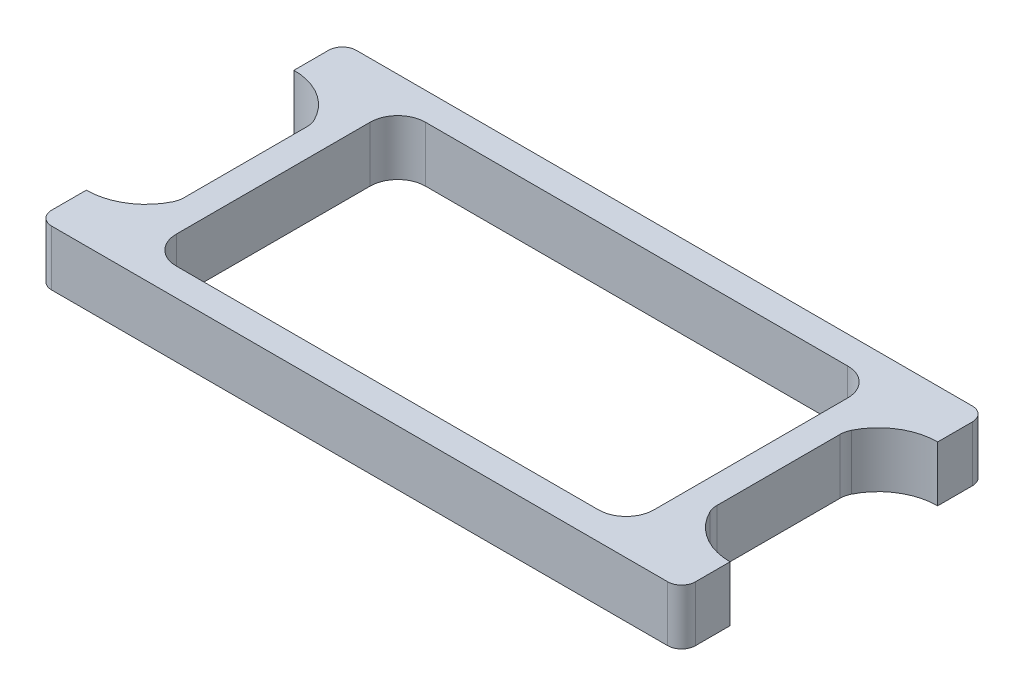
from build123d import *

# Parameters (mm, degrees)
SKETCH1_W            = 93
SKETCH1_H            = 44
BOSS_EXTRUDE1_DEPTH  = 8
SKETCH2_W            = 69
SKETCH2_H            = 36
CUT_EXTRUDE1_DEPTH   = 8
FILLET1_R            = 4
FILLET2_R            = 2
CUT_EXTRUDE2_START   = -9
CUT_EXTRUDE2_DEPTH   = 10
FILLET3_R            = 3
FILLET3_OF_MIRROR1_R = 3


with BuildPart() as part:
    # Sketch1 → Boss-Extrude1 (new body)
    with BuildSketch(Plane(origin=(0, 0, 0), x_dir=(1, 0, 0), z_dir=(0, 1, 0))):
        Rectangle(SKETCH1_W, SKETCH1_H)
    extrude(amount=BOSS_EXTRUDE1_DEPTH)

    # Sketch2 → Cut-Extrude1 (cut)
    with BuildSketch(Plane(origin=(0, 8, 0), x_dir=(1, 0, 0), z_dir=(0, 1, 0))):
        Rectangle(SKETCH2_W, SKETCH2_H)
    extrude(amount=-CUT_EXTRUDE1_DEPTH, mode=Mode.SUBTRACT)

    # Fillet1
    fillet1_edges = [part.edges().sort_by_distance(p)[0] for p in [
        (34.5, 4, 18),
        (-34.5, 4, 18),
        (-34.5, 4, -18),
        (34.5, 4, -18),
    ]]
    fillet(fillet1_edges, radius=FILLET1_R)

    # Fillet2
    fillet2_edges = [part.edges().sort_by_distance(p)[0] for p in [
        (-46.5, 4, -22),
        (46.5, 4, -22),
        (46.5, 4, 22),
        (-46.5, 4, 22),
    ]]
    fillet(fillet2_edges, radius=FILLET2_R)

    # Sketch3 → Cut-Extrude2 (cut)
    with BuildSketch(Plane(origin=(0, 8, 0), x_dir=(1, 0, 0), z_dir=(0, 1, 0)).offset(CUT_EXTRUDE2_START)):
        with BuildLine():
            Line((-38.5, 9.522429027), (-38.5, -9.522429027))
            ThreePointArc((-38.5, -9.522429027), (-41.652222577, -13.499394615), (-46.5, -15))
            Line((-46.5, -15), (-46.5, 15))
            ThreePointArc((-46.5, 15), (-41.652222577, 13.499394615), (-38.5, 9.522429027))
        make_face()
    cut_extrude2 = extrude(amount=CUT_EXTRUDE2_DEPTH, mode=Mode.SUBTRACT)

    # Fillet3
    fillet3_edges = [part.edges().sort_by_distance(p)[0] for p in [
        (-38.5, 4, -9.522429027),
        (-38.5, 4, 9.522429027),
    ]]
    fillet(fillet3_edges, radius=FILLET3_R)

    # Mirror1: Cut-Extrude2 across plane
    add(cut_extrude2.mirror(Plane(origin=(0, 0, 0), x_dir=(0, 0, 1), z_dir=(1, 0, 0))), mode=Mode.SUBTRACT)

    # Fillet3 of Mirror1
    fillet3_of_mirror1_edges = [part.edges().sort_by_distance(p)[0] for p in [
        (38.5, 4, -9.522429027),
        (38.5, 4, 9.522429027),
    ]]
    fillet(fillet3_of_mirror1_edges, radius=FILLET3_OF_MIRROR1_R)


solid = part.part
